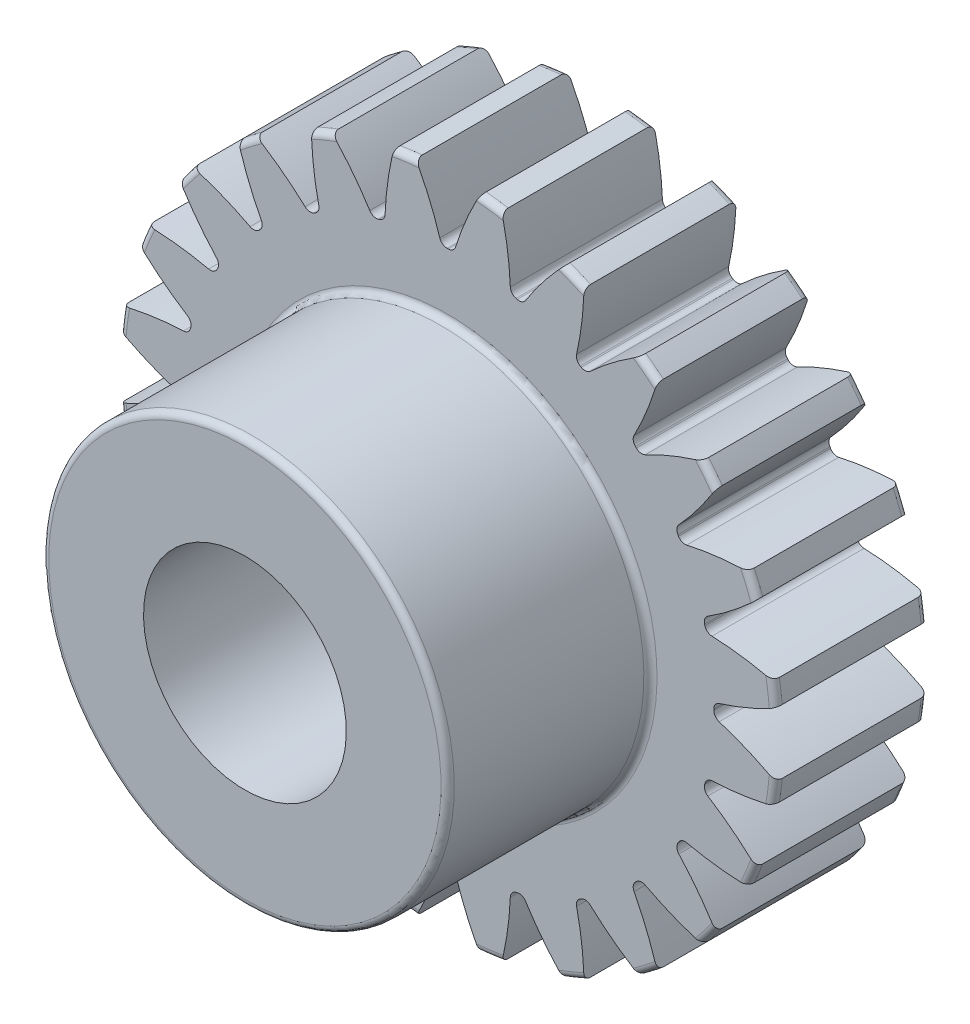
from build123d import *

# Parameters (mm, degrees)
FILLET2_R          = 0.13
CUT_EXTRUDE2_DEPTH = 4
CIRPATTERN1_COUNT  = 24


with BuildPart() as part:
    # Sketch4 → Revolve1 (revolve)
    with BuildSketch(Plane(origin=(0, 0, 0), x_dir=(0, 0, -1), z_dir=(1, 0, 0))):
        Polygon((-7, 2), (-7, 4), (-3, 4), (-3, 6.5), (0, 6.5), (0, 2), align=None)
    revolve(axis=Axis((0, 0, 3), (0, 0, 1)))

    # Fillet2
    fillet2_edges = [part.edges().sort_by_distance(p)[0] for p in [
        (0, -6.5, 0),
        (0, -6.5, 3),
        (0, -4, 3),
        (0, -4, 7),
    ]]
    fillet(fillet2_edges, radius=FILLET2_R)

    # Sketch7 → Cut-Extrude2 (cut, through all)
    with BuildSketch(Plane.XY.offset(3)):
        with BuildLine():
            ThreePointArc((-0.012291339, 5.249985612), (0, 5.25), (0.012291339, 5.249985612))
            ThreePointArc((0.012291339, 5.249985612), (0.10141019, 5.279068119), (0.155863571, 5.355375334))
            ThreePointArc((0.155863571, 5.355375334), (0.365213913, 5.92435749), (0.630915262, 6.469307995))
            ThreePointArc((0.630915262, 6.469307995), (0, 6.5), (-0.630915262, 6.469307995))
            ThreePointArc((-0.630915262, 6.469307995), (-0.365213913, 5.92435749), (-0.155863571, 5.355375334))
            ThreePointArc((-0.155863571, 5.355375334), (-0.10141019, 5.279068119), (-0.012291339, 5.249985612))
        make_face()
    cut_extrude2 = extrude(amount=-CUT_EXTRUDE2_DEPTH, mode=Mode.SUBTRACT)

    # CirPattern1: Cut-Extrude2 ×24 about axis
    cirpattern1_axis = Axis((0, 0, 0), (0, 0, 1))
    for i in range(1, CIRPATTERN1_COUNT):
        add(cut_extrude2.rotate(cirpattern1_axis, i * 360 / CIRPATTERN1_COUNT), mode=Mode.SUBTRACT)


solid = part.part
